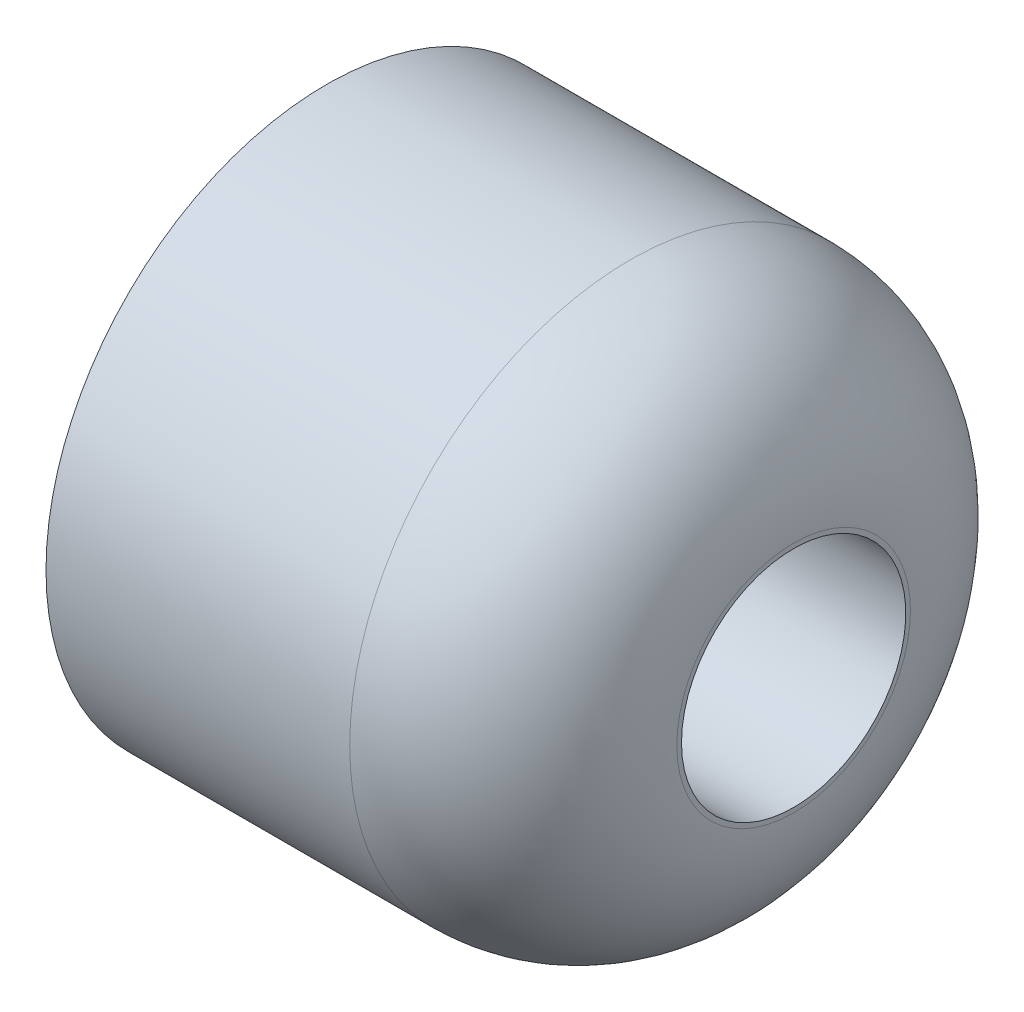
from build123d import *


with BuildPart() as part:
    # Sketch1 → Revolve1 (revolve)
    with BuildSketch(Plane(origin=(0, 0, 0), x_dir=(-1, 0, 0), z_dir=(0, 1, 0))):
        with BuildLine():
            Line((-10, 2.4), (0, 2.4))
            Line((0, 2.4), (0, 3.9))
            Line((0, 3.9), (-6, 3.9))
            Line((-6, 3.9), (-6, 5.5))
            Line((-6, 5.5), (0, 5.5))
            Line((0, 5.5), (0, 6))
            Line((0, 6), (-6.5, 6))
            ThreePointArc((-6.5, 6), (-8.974873734, 4.974873734), (-10, 2.5))
            Line((-10, 2.5), (-10, 2.4))
        make_face()
    revolve(axis=Axis((0, 0, 0), (1, 0, 0)))


solid = part.part
